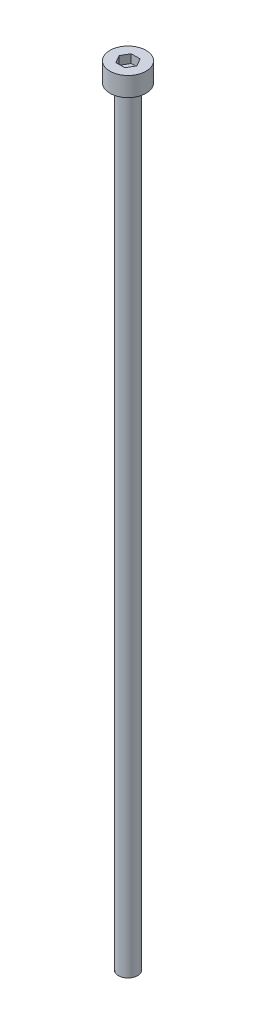
from build123d import *

# Parameters (mm, degrees)
SKETCH_1_R            = 2.35
EXTRUDE_248_DEPTH     = 2.5
CUT_EXTRUDE_382_DEPTH = 1.1
SKETCH_3_R            = 1.25
EXTRUDE_487_DEPTH     = 100


with BuildPart() as part:
    # 草图1 → Extrude 248 (new body)
    with BuildSketch(Plane(origin=(0, 0, 0), x_dir=(1, 0, 0), z_dir=(0, 1, 0))):
        Circle(SKETCH_1_R)
    extrude(amount=EXTRUDE_248_DEPTH)

    # 草图2 → Cut-Extrude 382 (cut)
    with BuildSketch(Plane(origin=(0, 2.5, 0), x_dir=(1, 0, 0), z_dir=(0, 1, 0))):
        Polygon((1.154700538, 0), (0.577350269, 1), (-0.577350269, 1), (-1.154700538, 0), (-0.577350269, -1), (0.577350269, -1), align=None)
    extrude(amount=-CUT_EXTRUDE_382_DEPTH, mode=Mode.SUBTRACT)

    # 草图3 → Extrude 487 (add)
    with BuildSketch(Plane.XZ):
        Circle(SKETCH_3_R)
    extrude(amount=EXTRUDE_487_DEPTH)


solid = part.part
